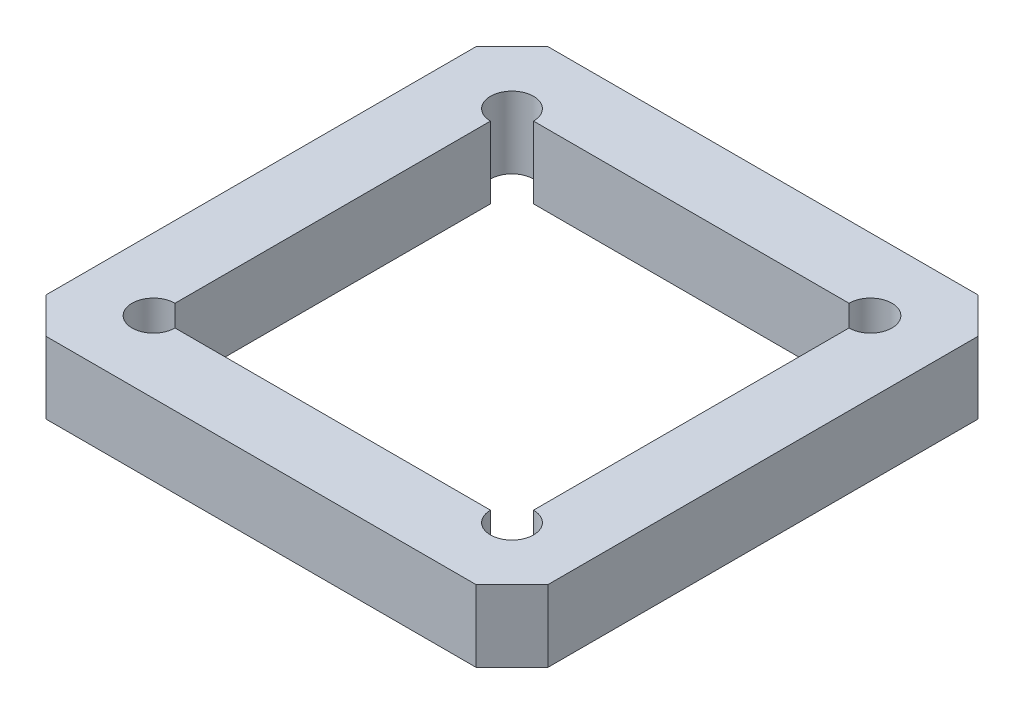
from build123d import *

# Parameters (mm, degrees)
BOSS_EXTRUDE1_DEPTH = 10
SKETCH2_R           = 4
CUT_EXTRUDE1_DEPTH  = 5


with BuildPart() as part:
    # Sketch1 → Boss-Extrude1 (new body)
    with BuildSketch(Plane(origin=(0, 0, 0), x_dir=(1, 0, 0), z_dir=(0, 1, 0))):
        Polygon((2.781569966, 65), (2.781569966, 5), (7.781569966, 0), (67.781569966, 0), (72.781569966, 5), (72.781569966, 65), (67.781569966, 70), (7.781569966, 70), align=None)
        with BuildLine():
            ThreePointArc((12.781569966, 57), (10.660249622, 62.121320344), (15.781569966, 60))
            Line((15.781569966, 60), (59.781569966, 60))
            ThreePointArc((59.781569966, 60), (62.781569966, 63), (65.781569966, 60))
            ThreePointArc((65.781569966, 60), (64.902890309, 57.878679656), (62.781569966, 57))
            Line((62.781569966, 57), (62.781569966, 13))
            ThreePointArc((62.781569966, 13), (64.902890309, 12.121320344), (65.781569966, 10))
            ThreePointArc((65.781569966, 10), (62.781569966, 7), (59.781569966, 10))
            Line((59.781569966, 10), (15.781569966, 10))
            ThreePointArc((15.781569966, 10), (10.660249622, 7.878679656), (12.781569966, 13))
            Line((12.781569966, 13), (12.781569966, 57))
        make_face(mode=Mode.SUBTRACT)
    extrude(amount=BOSS_EXTRUDE1_DEPTH)

    # Sketch2 → Cut-Extrude1 (cut)
    with BuildSketch(Plane.XZ):
        with Locations((22.781569966, -5)):
            Circle(SKETCH2_R)
        with Locations((52.681064902, -5)):
            Circle(SKETCH2_R)
        with Locations((67.781569966, -20)):
            Circle(SKETCH2_R)
        with Locations((67.781569966, -50)):
            Circle(SKETCH2_R)
        with Locations((52.681064902, -64.899494937)):
            Circle(SKETCH2_R)
        with Locations((22.781569966, -64.899494937)):
            Circle(SKETCH2_R)
        with Locations((7.831822498, -50)):
            Circle(SKETCH2_R)
        with Locations((7.831822498, -20)):
            Circle(SKETCH2_R)
    extrude(amount=-CUT_EXTRUDE1_DEPTH, mode=Mode.SUBTRACT)


solid = part.part
